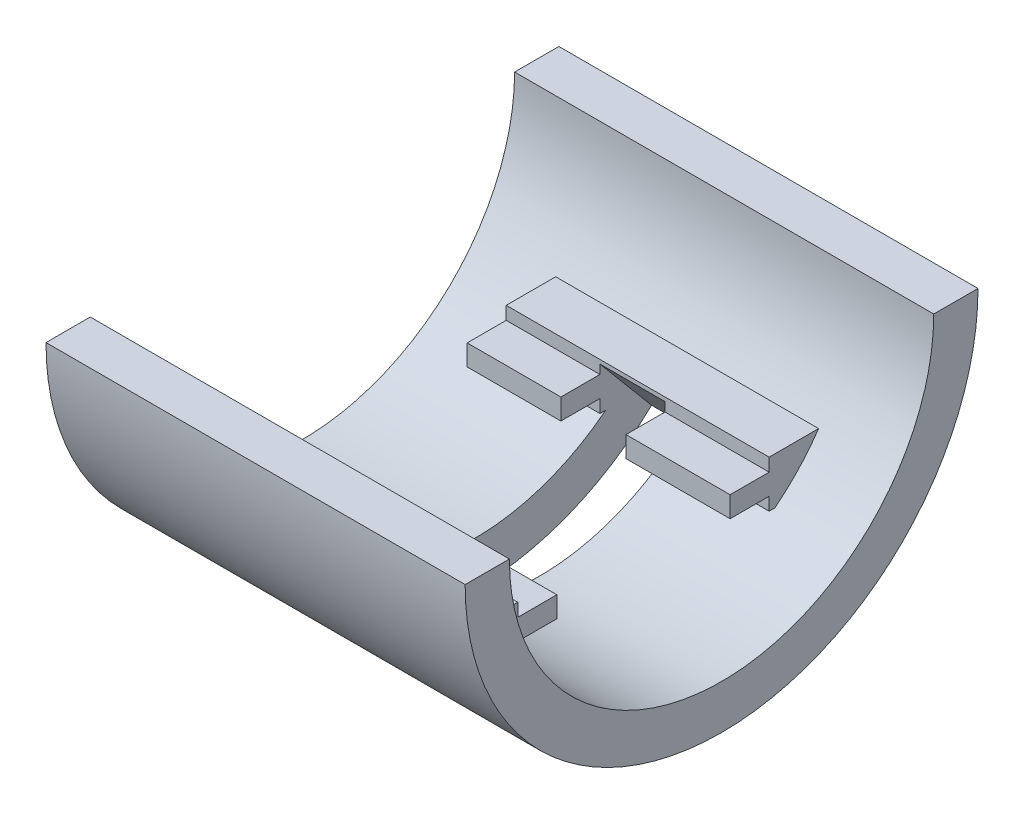
from build123d import *

# Parameters (mm, degrees)
SKETCH1_W                       = 40.894
SKETCH1_H                       = 25.4
REVOLVE1_ANGLE                  = 180
BOSS_EXTRUDE1_REACH             = 27.4
SKETCH3_W                       = 25.654
SKETCH3_H                       = 4.572
BOSS_EXTRUDE1_DIRECTION_2_REACH = 27.4
SKETCH4_W                       = 25.654
SKETCH4_H                       = 24.524924672
CUT_EXTRUDE1_DEPTH              = 4.572
SKETCH5_W                       = 3.81
SKETCH5_H                       = 2.032
BOSS_EXTRUDE2_DEPTH             = 25.654
SKETCH8_W                       = 6.35
SKETCH8_H                       = 30.865764514
CUT_REVOLVE2_ANGLE              = 40
CUT_REVOLVE2_OTHER_WAY_ANGLE    = 40
CUT_EXTRUDE3_DEPTH              = 45.72


with BuildPart() as part:
    # Sketch1 → Revolve1 (revolve)
    with BuildSketch(Plane(origin=(0, 0, 0), x_dir=(1, 0, 0), z_dir=(0, 1, 0))):
        with Locations((20.447, -12.7)):
            Rectangle(SKETCH1_W, SKETCH1_H)
    revolve(axis=Axis((0, 0, 0), (1, 0, 0)), revolution_arc=REVOLVE1_ANGLE)

    # Sketch2 → Cut-Revolve1 (revolve, cut)
    with BuildSketch(Plane(origin=(0, 0, 0), x_dir=(1, 0, 0), z_dir=(0, 1, 0))):
        Polygon((0, 0), (41.402, 0), (41.402, -20.701), (40.132, -20.701), (1.27, -20.701), (0, -20.701), align=None)
    revolve(axis=Axis((0, 0, 0), (1, 0, 0)), mode=Mode.SUBTRACT)

    # Sketch3 → Boss-Extrude1 (add, up to next)
    with BuildSketch(Plane.XY, mode=Mode.PRIVATE) as boss_extrude1_sk1:
        with Locations((20.447, -13.97)):
            Rectangle(SKETCH3_W, SKETCH3_H)
    boss_extrude1_tool1 = extrude(boss_extrude1_sk1.sketch, amount=BOSS_EXTRUDE1_REACH, mode=Mode.PRIVATE) - part.part
    add(boss_extrude1_tool1.solids().sort_by_distance((20.447, -13.97, 0))[0])

    # Sketch3 → Boss-Extrude1 direction 2 (add, up to next)
    with BuildSketch(Plane.XY, mode=Mode.PRIVATE) as boss_extrude1_direction_2_sk1:
        with Locations((20.447, -13.97)):
            Rectangle(SKETCH3_W, SKETCH3_H)
    boss_extrude1_direction_2_tool1 = extrude(boss_extrude1_direction_2_sk1.sketch, amount=-BOSS_EXTRUDE1_DIRECTION_2_REACH, mode=Mode.PRIVATE) - part.part
    add(boss_extrude1_direction_2_tool1.solids().sort_by_distance((20.447, -13.97, 0))[0])

    # Sketch4 → Cut-Extrude1 (cut)
    with BuildSketch(Plane(origin=(0, -11.684, 0), x_dir=(1, 0, 0), z_dir=(0, 1, 0))):
        with Locations((20.447, 0)):
            Rectangle(SKETCH4_W, SKETCH4_H)
    extrude(amount=-CUT_EXTRUDE1_DEPTH, mode=Mode.SUBTRACT)

    # Sketch5 → Boss-Extrude2 (add)
    with BuildSketch(Plane.ZY.offset(-7.62)):
        with Locations((-10.357462336, -13.97)):
            Rectangle(SKETCH5_W, SKETCH5_H)
        with Locations((10.357462336, -13.97)):
            Rectangle(SKETCH5_W, SKETCH5_H)
    extrude(amount=-BOSS_EXTRUDE2_DEPTH)

    # Sketch8 → Cut-Revolve2 (revolve, cut)
    with BuildSketch(Plane.XY):
        with Locations((19.939, -12.892882257)):
            Rectangle(SKETCH8_W, SKETCH8_H)
    revolve(axis=Axis((23.114, 2.54, 0), (-1, 0, 0)), revolution_arc=CUT_REVOLVE2_ANGLE, mode=Mode.SUBTRACT)

    # Sketch8 → Cut-Revolve2 other way (revolve, cut)
    with BuildSketch(Plane.XY):
        with Locations((19.939, -12.892882257)):
            Rectangle(SKETCH8_W, SKETCH8_H)
    revolve(axis=Axis((23.114, 2.54, 0), (1, 0, 0)), revolution_arc=CUT_REVOLVE2_OTHER_WAY_ANGLE, mode=Mode.SUBTRACT)

    # Sketch9 → Cut-Extrude3 (cut)
    with BuildSketch(Plane(origin=(40.894, 0, 0), x_dir=(0, 0, -1), z_dir=(1, 0, 0))):
        with BuildLine():
            ThreePointArc((25.019, 0), (0, -25.019), (-25.019, 0))
            Line((-25.019, 0), (-25.4, 0))
            ThreePointArc((-25.4, 0), (0, -25.4), (25.4, 0))
            Line((25.4, 0), (25.019, 0))
        make_face()
    extrude(amount=-CUT_EXTRUDE3_DEPTH, mode=Mode.SUBTRACT)


solid = part.part
